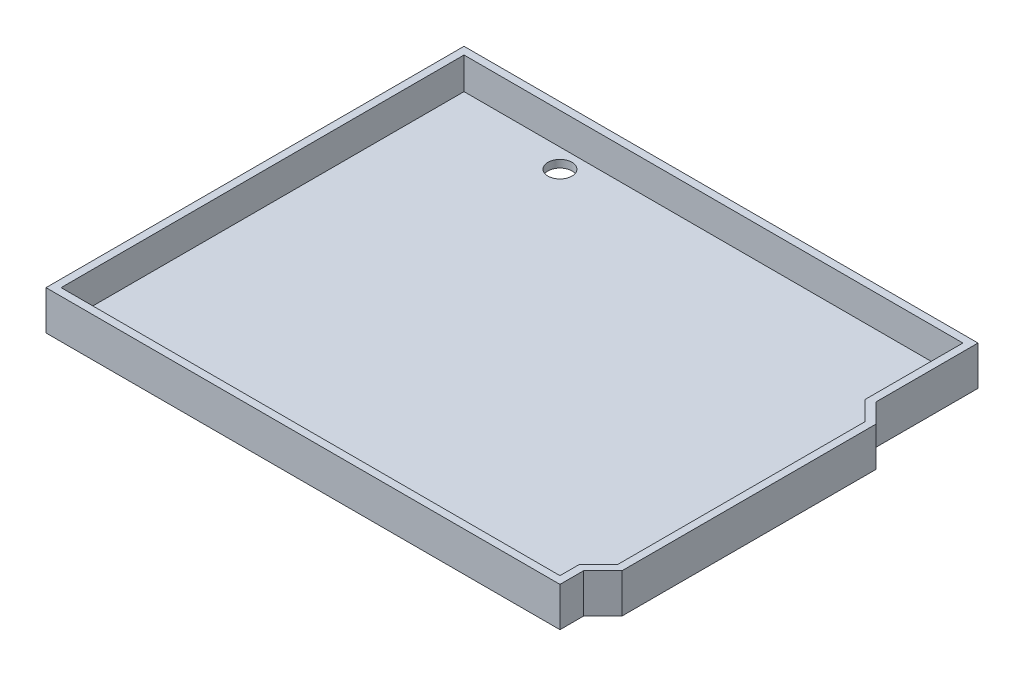
from build123d import *

# Parameters (mm, degrees)
SKETCH1_R           = 1.59
BOSS_EXTRUDE1_DEPTH = 5.2
SKETCH1_5_R         = 1.59
CUT_EXTRUDE2_DEPTH  = 4.2


with BuildPart() as part:
    # Sketch1 → Boss-Extrude1 (new body)
    with BuildSketch(Plane(origin=(0, 0, 0), x_dir=(1, 0, 0), z_dir=(0, 1, 0))):
        Polygon((36.56, 11.594213562), (34.02, 14.134213562), (34.02, 27.67), (-34.02, 27.67), (-34.02, -27.67), (34.02, -27.67), (34.02, -24.544213562), (36.56, -22.004213562), align=None)
        with Locations((-19.05, -24.13)):
            Circle(SKETCH1_R, mode=Mode.SUBTRACT)
        with Locations((33.02, -19.05)):
            Circle(SKETCH1_R, mode=Mode.SUBTRACT)
        with Locations((-17.78, 24.13)):
            Circle(SKETCH1_R, mode=Mode.SUBTRACT)
        with Locations((33.02, 8.89)):
            Circle(SKETCH1_R, mode=Mode.SUBTRACT)
    extrude(amount=-BOSS_EXTRUDE1_DEPTH)

    # Sketch1_5 → Cut-Extrude2 (cut)
    with BuildSketch(Plane(origin=(0, 0, 0), x_dir=(1, 0, 0), z_dir=(0, 1, 0))):
        Polygon((-33.02, -26.67), (33.02, -26.67), (33.02, -24.13), (35.56, -21.59), (35.56, 11.18), (33.02, 13.72), (33.02, 26.67), (-33.02, 26.67), align=None)
        with Locations((-19.05, -24.13)):
            Circle(SKETCH1_5_R, mode=Mode.SUBTRACT)
        with Locations((33.02, -19.05)):
            Circle(SKETCH1_5_R, mode=Mode.SUBTRACT)
        with Locations((-17.78, 24.13)):
            Circle(SKETCH1_5_R, mode=Mode.SUBTRACT)
        with Locations((33.02, 8.89)):
            Circle(SKETCH1_5_R, mode=Mode.SUBTRACT)
    extrude(amount=-CUT_EXTRUDE2_DEPTH, mode=Mode.SUBTRACT)


solid = part.part
